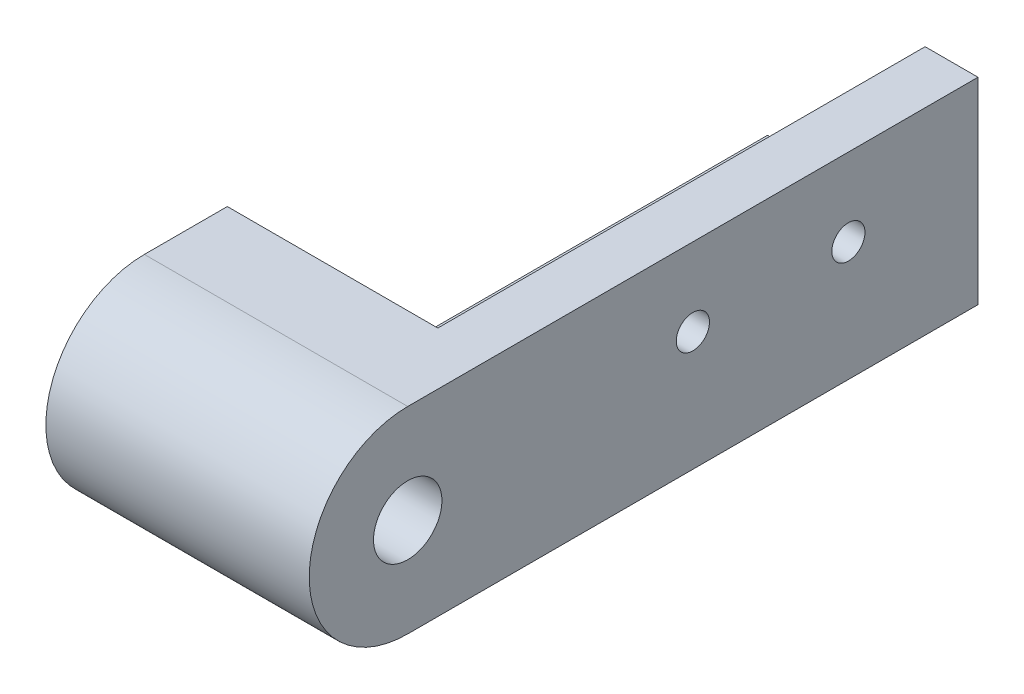
from build123d import *

# Parameters (mm, degrees)
BOSS_EXTRUDE1_DEPTH = 50
SKETCH2_W           = 25.4
SKETCH2_H           = 19
BOSS_EXTRUDE2_DEPTH = 25.4
SKETCH3_R           = 3.3
CUT_EXTRUDE1_DEPTH  = 25.4
SKETCH4_R           = 1.6
SKETCH4_R_2         = 1.60271378
CUT_EXTRUDE2_DEPTH  = 25.4
SKETCH5_R           = 1.746858549
SKETCH5_R_2         = 1.6
CUT_EXTRUDE3_DEPTH  = 20
SKETCH6_W           = 5.1
SKETCH6_H           = 47
CUT_EXTRUDE4_DEPTH  = 20
SKETCH7_W           = 15.2
SKETCH7_H           = 3
BOSS_EXTRUDE3_DEPTH = 15


with BuildPart() as part:
    # Sketch1 → Boss-Extrude1 (new body)
    with BuildSketch(Plane.XY):
        Polygon((0, 0), (0, 15), (-5.1, 15), (-5.1, -4), (20.3, -4), (20.3, 15), (15.2, 15), (15.2, 0), align=None)
    extrude(amount=BOSS_EXTRUDE1_DEPTH)

    # Sketch2 → Boss-Extrude2 (add)
    with BuildSketch(Plane.XY.offset(50)):
        with Locations((7.6, 5.5)):
            Rectangle(SKETCH2_W, SKETCH2_H)
    extrude(amount=BOSS_EXTRUDE2_DEPTH)

    # Sketch3 → Cut-Extrude1 (cut)
    with BuildSketch(Plane(origin=(20.3, 0, 0), x_dir=(0, 0, -1), z_dir=(1, 0, 0))):
        with Locations((-55, 5.5)):
            Circle(SKETCH3_R)
        with BuildLine():
            Line((-55, -4), (-75.4, -4))
            Line((-75.4, -4), (-75.4, 15))
            Line((-75.4, 15), (-55, 15))
            ThreePointArc((-55, 15), (-64.5, 5.5), (-55, -4))
        make_face()
    extrude(amount=-CUT_EXTRUDE1_DEPTH, mode=Mode.SUBTRACT)

    # Sketch4 → Cut-Extrude2 (cut)
    with BuildSketch(Plane(origin=(20.3, 0, 0), x_dir=(0, 0, -1), z_dir=(1, 0, 0))):
        with Locations((-12.5, 7.5)):
            Circle(SKETCH4_R)
        with Locations((-27.5, 7.5)):
            Circle(SKETCH4_R_2)
    extrude(amount=-CUT_EXTRUDE2_DEPTH, mode=Mode.SUBTRACT)

    # Sketch5 → Cut-Extrude3 (cut, through all)
    with BuildSketch(Plane.XZ.offset(4)):
        with Locations((7.6, 12.5)):
            Circle(SKETCH5_R)
        with Locations((7.6, 27.5)):
            Circle(SKETCH5_R_2)
    extrude(amount=-CUT_EXTRUDE3_DEPTH, mode=Mode.SUBTRACT)

    # Sketch6 → Cut-Extrude4 (cut, through all)
    with BuildSketch(Plane(origin=(0, 15, 0), x_dir=(1, 0, 0), z_dir=(0, 1, 0))):
        with Locations((-2.55, -23.5)):
            Rectangle(SKETCH6_W, SKETCH6_H)
    extrude(amount=-CUT_EXTRUDE4_DEPTH, mode=Mode.SUBTRACT)

    # Sketch7 → Boss-Extrude3 (add)
    with BuildSketch(Plane(origin=(0, 0, 0), x_dir=(1, 0, 0), z_dir=(0, 1, 0))):
        with Locations((7.6, -48.5)):
            Rectangle(SKETCH7_W, SKETCH7_H)
    extrude(amount=BOSS_EXTRUDE3_DEPTH)


solid = part.part
